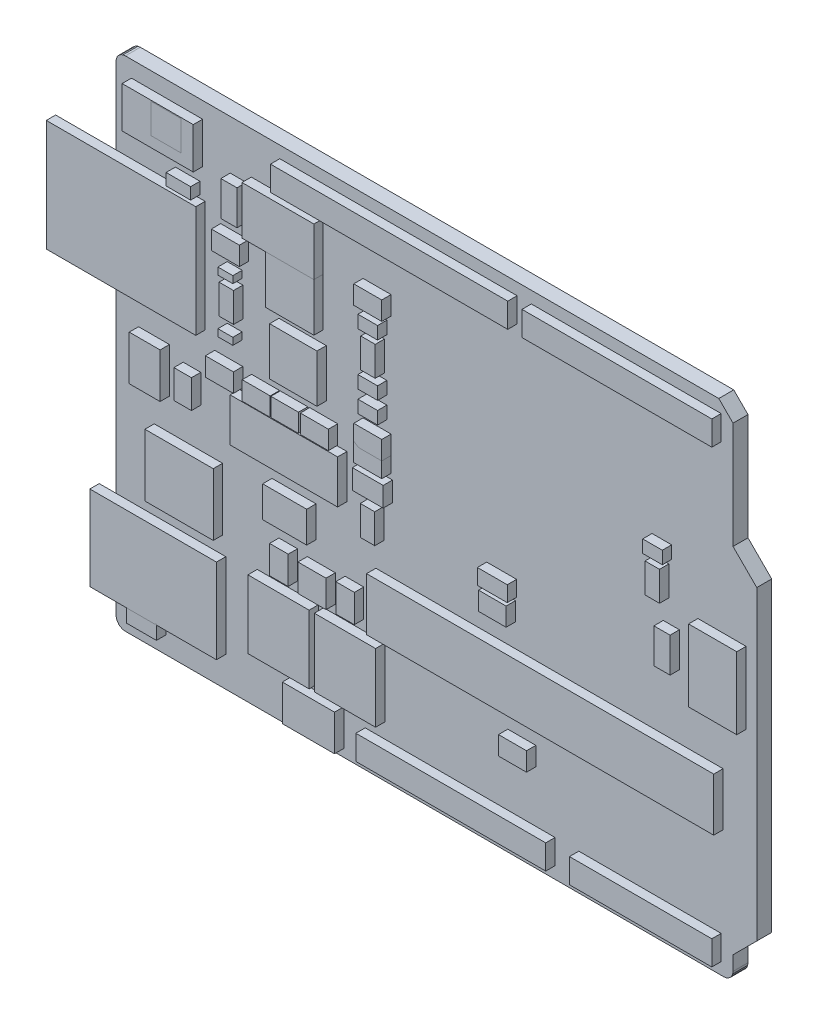
from build123d import *

# Parameters (mm, degrees)
BOARD_DEPTH                 = 1.6
SKETCH2_W                   = 15.24
SKETCH2_H                   = 2.6162
EXTRUDE_1X06_1_DEPTH        = 1
SKETCH3_W                   = 1.9914
SKETCH3_H                   = 2.9968
C0603_ROUND_1_DEPTH         = 1
SKETCH4_W                   = 2.9968
SKETCH4_H                   = 1.9914
C0603_ROUND_2_DEPTH         = 1
SKETCH5_W                   = 1.9914
SKETCH5_H                   = 2.9968
C0603_ROUND_3_DEPTH         = 1
SKETCH6_W                   = 2.9968
SKETCH6_H                   = 1.9914
C0603_ROUND_4_DEPTH         = 1
SKETCH7_W                   = 2.9968
SKETCH7_H                   = 1.9914
C0603_ROUND_5_DEPTH         = 1
SKETCH8_W                   = 2.9968
SKETCH8_H                   = 1.9914
C0603_ROUND_6_DEPTH         = 1
SKETCH9_W                   = 2.9968
SKETCH9_H                   = 1.9914
C0603_ROUND_7_DEPTH         = 1
SKETCH10_W                  = 2.9968
SKETCH10_H                  = 1.9914
C0603_ROUND_8_DEPTH         = 1
SKETCH11_W                  = 2.9968
SKETCH11_H                  = 1.9914
C0603_ROUND_9_DEPTH         = 1
SKETCH12_W                  = 2.9968
SKETCH12_H                  = 1.9914
C0603_ROUND_10_DEPTH        = 1
SKETCH13_W                  = 5.588
SKETCH13_H                  = 3.8608
SMB_1_DEPTH                 = 1
SKETCH14_W                  = 1.7272
SKETCH14_H                  = 3.7084
MINIMELF_1_DEPTH            = 1
SKETCH15_W                  = 1.7272
SKETCH15_H                  = 3.7084
MINIMELF_2_DEPTH            = 1
SKETCH16_W                  = 3.302
SKETCH16_H                  = 4.7854
EXTRUDE_L1812_1_DEPTH       = 1
SKETCH17_W                  = 3.1844
SKETCH17_H                  = 3.1844
FIDUCIA_MOUNT_1_DEPTH       = 1
SKETCH18_W                  = 3.1844
SKETCH18_H                  = 3.1844
FIDUCIA_MOUNT_2_DEPTH       = 1
SKETCH19_W                  = 3.1844
SKETCH19_H                  = 3.1844
FIDUCIA_MOUNT_3_DEPTH       = 1
SKETCH20_W                  = 3.302
SKETCH20_H                  = 2.1082
SJ_1_DEPTH                  = 1
SKETCH21_W                  = 5.1562
SKETCH21_H                  = 7.6962
EXTRUDE_2X03_1_DEPTH        = 1
SKETCH22_W                  = 7.6962
SKETCH22_H                  = 5.1562
EXTRUDE_2X03_2_DEPTH        = 1
SKETCH23_W                  = 25.4
SKETCH23_H                  = 2.6162
EXTRUDE_1X10_1_DEPTH        = 1
SKETCH24_W                  = 20.32
SKETCH24_H                  = 2.6162
EXTRUDE_1X08_1_DEPTH        = 1
SKETCH25_W                  = 20.32
SKETCH25_H                  = 2.6162
EXTRUDE_1X08_2_DEPTH        = 1
SKETCH26_W                  = 5.1562
SKETCH26_H                  = 5.1562
EXTRUDE_2X02_1_DEPTH        = 1
SKETCH27_W                  = 2.1
SKETCH27_H                  = 1.3508
CHIP_LED0805_1_DEPTH        = 1
SKETCH28_W                  = 2.1
SKETCH28_H                  = 1.3508
CHIP_LED0805_2_DEPTH        = 1
SKETCH29_W                  = 2.1
SKETCH29_H                  = 1.3508
CHIP_LED0805_3_DEPTH        = 1
SKETCH30_W                  = 2.1
SKETCH30_H                  = 1.3508
CHIP_LED0805_4_DEPTH        = 1
SKETCH31_W                  = 2.627
SKETCH31_H                  = 1.25
EXTRUDE_0805_1_DEPTH        = 1
SKETCH32_W                  = 6.5508
SKETCH32_H                  = 7.3
PANASONIC_D_1_DEPTH         = 1
SKETCH33_W                  = 6.5508
SKETCH33_H                  = 7.3
PANASONIC_D_2_DEPTH         = 1
SKETCH34_W                  = 2.946
SKETCH34_H                  = 1.966
R0603_ROUND_1_DEPTH         = 1
SKETCH35_W                  = 2.946
SKETCH35_H                  = 1.966
R0603_ROUND_2_DEPTH         = 1
SKETCH36_W                  = 7.6125
SKETCH36_H                  = 4.4
TS42_1_DEPTH                = 1
SKETCH37_W                  = 3.302
SKETCH37_H                  = 2.1082
SJ_2_DEPTH                  = 1
SKETCH38_W                  = 1.5508
SKETCH38_H                  = 3.1508
CAY16_1_DEPTH               = 1
SKETCH39_W                  = 1.5508
SKETCH39_H                  = 3.1508
CAY16_2_DEPTH               = 1
SKETCH40_W                  = 1.5508
SKETCH40_H                  = 3.1508
CAY16_3_DEPTH               = 1
SKETCH41_W                  = 1.5508
SKETCH41_H                  = 3.1508
CAY16_4_DEPTH               = 1
SKETCH42_W                  = 1.8796
SKETCH42_H                  = 3.048
SOT_23_1_DEPTH              = 1
SKETCH44_W                  = 7.3152
SKETCH44_H                  = 6.6548
SOT223_1_DEPTH              = 1
SKETCH45_W                  = 3
SKETCH45_H                  = 2.9202
SOT23_DBV_1_DEPTH           = 1
SKETCH46_W                  = 5.0635
SKETCH46_H                  = 5.127
MLF32_1_DEPTH               = 1
SKETCH47_W                  = 4.7126
SKETCH47_H                  = 3.3262
MSOP08_1_DEPTH              = 1
SKETCH48_W                  = 13.5509
SKETCH48_H                  = 9.0551
POWERSUPPLY_DC_21MM_1_DEPTH = 1
SKETCH49_W                  = 16.004
SKETCH49_H                  = 11.927
PN61729_1_DEPTH             = 1
SKETCH50_W                  = 11.5062
SKETCH50_H                  = 4.6482
QS_1_DEPTH                  = 1
SKETCH51_W                  = 3.2
SKETCH51_H                  = 1.6635
RESONATOR_1_DEPTH           = 1
SKETCH52_W                  = 1.6016
SKETCH52_H                  = 0.7508
CT_CN0603_1_DEPTH           = 1
SKETCH53_W                  = 1.6016
SKETCH53_H                  = 0.7508
CT_CN0603_2_DEPTH           = 1
SKETCH54_W                  = 37.1602
SKETCH54_H                  = 5.6642
DIL28_3_1_DEPTH             = 1


with BuildPart() as part:
    # Sketch1 → BOARD (new body)
    with BuildSketch(Plane.XY):
        Polygon((64.516, 53.34), (66.04, 51.816), (66.04, 40.386), (68.58, 37.846), (68.58, 5.08), (66.04, 2.54), (66.04, 1), (66.005926, 0.741181), (65.906025, 0.5), (65.747107, 0.292893), (65.54, 0.133975), (65.298819, 0.034074), (65.04, 0), (1, 0), (0.741181, 0.034074), (0.5, 0.133975), (0.292893, 0.292893), (0.133975, 0.5), (0.034074, 0.741181), (0, 1), (0, 52.34), (0.034074, 52.598819), (0.133975, 52.84), (0.292893, 53.047107), (0.5, 53.206025), (0.741181, 53.305926), (1, 53.34), align=None)
    extrude(amount=BOARD_DEPTH)


with BuildPart() as body_2:
    # Sketch2 → Extrude 1X06-1 (new body)
    with BuildSketch(Plane.XY.offset(1.6)):
        with Locations((57.15, 2.5781)):
            Rectangle(SKETCH2_W, SKETCH2_H)
    extrude(amount=EXTRUDE_1X06_1_DEPTH)


with BuildPart() as body_3:
    # Sketch3 → C0603-ROUND-1 (new body)
    with BuildSketch(Plane.XY.offset(1.6)):
        with Locations((18.4277, 15.367)):
            Rectangle(SKETCH3_W, SKETCH3_H)
    extrude(amount=C0603_ROUND_1_DEPTH)


with BuildPart() as body_4:
    # Sketch4 → C0603-ROUND-2 (new body)
    with BuildSketch(Plane.XY.offset(1.6)):
        with Locations((12.065, 29.8323)):
            Rectangle(SKETCH4_W, SKETCH4_H)
    extrude(amount=C0603_ROUND_2_DEPTH)


with BuildPart() as body_5:
    # Sketch5 → C0603-ROUND-3 (new body)
    with BuildSketch(Plane.XY.offset(1.6)):
        with Locations((25.5143, 15.367)):
            Rectangle(SKETCH5_W, SKETCH5_H)
    extrude(amount=C0603_ROUND_3_DEPTH)


with BuildPart() as body_6:
    # Sketch6 → C0603-ROUND-4 (new body)
    with BuildSketch(Plane.XY.offset(1.6)):
        with Locations((27.94, 44.4373)):
            Rectangle(SKETCH6_W, SKETCH6_H)
    extrude(amount=C0603_ROUND_4_DEPTH)


with BuildPart() as body_7:
    # Sketch7 → C0603-ROUND-5 (new body)
    with BuildSketch(Plane.XY.offset(1.6)):
        with Locations((27.94, 29.8577)):
            Rectangle(SKETCH7_W, SKETCH7_H)
    extrude(amount=C0603_ROUND_5_DEPTH)


with BuildPart() as body_8:
    # Sketch8 → C0603-ROUND-6 (new body)
    with BuildSketch(Plane.XY.offset(1.6)):
        with Locations((43.434, 10.4013)):
            Rectangle(SKETCH8_W, SKETCH8_H)
    extrude(amount=C0603_ROUND_6_DEPTH)


with BuildPart() as body_9:
    # Sketch9 → C0603-ROUND-7 (new body)
    with BuildSketch(Plane.XY.offset(1.6)):
        with Locations((27.94, 31.5087)):
            Rectangle(SKETCH9_W, SKETCH9_H)
    extrude(amount=C0603_ROUND_7_DEPTH)


with BuildPart() as body_10:
    # Sketch10 → C0603-ROUND-8 (new body)
    with BuildSketch(Plane.XY.offset(1.6)):
        with Locations((12.7, 41.8973)):
            Rectangle(SKETCH10_W, SKETCH10_H)
    extrude(amount=C0603_ROUND_8_DEPTH)


with BuildPart() as body_11:
    # Sketch11 → C0603-ROUND-9 (new body)
    with BuildSketch(Plane.XY.offset(1.6)):
        with Locations((16.002, 29.5783)):
            Rectangle(SKETCH11_W, SKETCH11_H)
    extrude(amount=C0603_ROUND_9_DEPTH)


with BuildPart() as body_12:
    # Sketch12 → C0603-ROUND-10 (new body)
    with BuildSketch(Plane.XY.offset(1.6)):
        with Locations((22.225, 29.6037)):
            Rectangle(SKETCH12_W, SKETCH12_H)
    extrude(amount=C0603_ROUND_10_DEPTH)


with BuildPart() as body_13:
    # Sketch13 → SMB-1 (new body)
    with BuildSketch(Plane.XY.offset(1.6)):
        with Locations((21.59, 2.7686)):
            Rectangle(SKETCH13_W, SKETCH13_H)
    extrude(amount=SMB_1_DEPTH)


with BuildPart() as body_14:
    # Sketch14 → MINIMELF-1 (new body)
    with BuildSketch(Plane.XY.offset(1.6)):
        with Locations((59.436, 27.94)):
            Rectangle(SKETCH14_W, SKETCH14_H)
    extrude(amount=MINIMELF_1_DEPTH)


with BuildPart() as body_15:
    # Sketch15 → MINIMELF-2 (new body)
    with BuildSketch(Plane.XY.offset(1.6)):
        with Locations((13.081, 46.228)):
            Rectangle(SKETCH15_W, SKETCH15_H)
    extrude(amount=MINIMELF_2_DEPTH)


with BuildPart() as body_16:
    # Sketch16 → Extrude L1812-1 (new body)
    with BuildSketch(Plane.XY.offset(1.6)):
        with Locations((4.064, 26.5481)):
            Rectangle(SKETCH16_W, SKETCH16_H)
    extrude(amount=EXTRUDE_L1812_1_DEPTH)


with BuildPart() as body_17:
    # Sketch17 → FIDUCIA-MOUNT-1 (new body)
    with BuildSketch(Plane.XY.offset(1.6)):
        with Locations((6.35, 49.911)):
            Rectangle(SKETCH17_W, SKETCH17_H)
    extrude(amount=FIDUCIA_MOUNT_1_DEPTH)


with BuildPart() as body_18:
    # Sketch18 → FIDUCIA-MOUNT-2 (new body)
    with BuildSketch(Plane.XY.offset(1.6)):
        with Locations((53.84, 16.741)):
            Rectangle(SKETCH18_W, SKETCH18_H)
    extrude(amount=FIDUCIA_MOUNT_2_DEPTH)


with BuildPart() as body_19:
    # Sketch19 → FIDUCIA-MOUNT-3 (new body)
    with BuildSketch(Plane.XY.offset(1.6)):
        with Locations((3.73, 3.41)):
            Rectangle(SKETCH19_W, SKETCH19_H)
    extrude(amount=FIDUCIA_MOUNT_3_DEPTH)


with BuildPart() as body_20:
    # Sketch20 → SJ-1 (new body)
    with BuildSketch(Plane.XY):
        with Locations((11.43, 40.6019)):
            Rectangle(SKETCH20_W, SKETCH20_H)
    extrude(amount=-SJ_1_DEPTH)


with BuildPart() as body_21:
    # Sketch21 → Extrude 2X03-1 (new body)
    with BuildSketch(Plane.XY.offset(1.6)):
        with Locations((64.8589, 27.9781)):
            Rectangle(SKETCH21_W, SKETCH21_H)
    extrude(amount=EXTRUDE_2X03_1_DEPTH)


with BuildPart() as body_22:
    # Sketch22 → Extrude 2X03-2 (new body)
    with BuildSketch(Plane.XY.offset(1.6)):
        with Locations((18.3261, 46.2661)):
            Rectangle(SKETCH22_W, SKETCH22_H)
    extrude(amount=EXTRUDE_2X03_2_DEPTH)


with BuildPart() as body_23:
    # Sketch23 → Extrude 1X10-1 (new body)
    with BuildSketch(Plane.XY.offset(1.6)):
        with Locations((30.226, 50.7619)):
            Rectangle(SKETCH23_W, SKETCH23_H)
    extrude(amount=EXTRUDE_1X10_1_DEPTH)


with BuildPart() as body_24:
    # Sketch24 → Extrude 1X08-1 (new body)
    with BuildSketch(Plane.XY.offset(1.6)):
        with Locations((54.61, 50.7619)):
            Rectangle(SKETCH24_W, SKETCH24_H)
    extrude(amount=EXTRUDE_1X08_1_DEPTH)


with BuildPart() as body_25:
    # Sketch25 → Extrude 1X08-2 (new body)
    with BuildSketch(Plane.XY.offset(1.6)):
        with Locations((36.83, 2.5781)):
            Rectangle(SKETCH25_W, SKETCH25_H)
    extrude(amount=EXTRUDE_1X08_2_DEPTH)


with BuildPart() as body_26:
    # Sketch26 → Extrude 2X02-1 (new body)
    with BuildSketch(Plane.XY.offset(1.6)):
        with Locations((19.5961, 41.1099)):
            Rectangle(SKETCH26_W, SKETCH26_H)
    extrude(amount=EXTRUDE_2X02_1_DEPTH)


with BuildPart() as body_27:
    # Sketch27 → CHIP-LED0805-1 (new body)
    with BuildSketch(Plane.XY.offset(1.6)):
        with Locations((27.94, 42.1644)):
            Rectangle(SKETCH27_W, SKETCH27_H)
    extrude(amount=CHIP_LED0805_1_DEPTH)


with BuildPart() as body_28:
    # Sketch28 → CHIP-LED0805-2 (new body)
    with BuildSketch(Plane.XY.offset(1.6)):
        with Locations((58.42, 36.5764)):
            Rectangle(SKETCH28_W, SKETCH28_H)
    extrude(amount=CHIP_LED0805_2_DEPTH)


with BuildPart() as body_29:
    # Sketch29 → CHIP-LED0805-3 (new body)
    with BuildSketch(Plane.XY.offset(1.6)):
        with Locations((27.94, 34.2896)):
            Rectangle(SKETCH29_W, SKETCH29_H)
    extrude(amount=CHIP_LED0805_3_DEPTH)


with BuildPart() as body_30:
    # Sketch30 → CHIP-LED0805-4 (new body)
    with BuildSketch(Plane.XY.offset(1.6)):
        with Locations((27.94, 36.5756)):
            Rectangle(SKETCH30_W, SKETCH30_H)
    extrude(amount=CHIP_LED0805_4_DEPTH)


with BuildPart() as body_31:
    # Sketch31 → Extrude 0805-1 (new body)
    with BuildSketch(Plane.XY.offset(1.6)):
        with Locations((7.67, 45.085)):
            Rectangle(SKETCH31_W, SKETCH31_H)
    extrude(amount=EXTRUDE_0805_1_DEPTH)


with BuildPart() as body_32:
    # Sketch32 → PANASONIC_D-1 (new body)
    with BuildSketch(Plane.XY.offset(1.6)):
        with Locations((25.5016, 9.144)):
            Rectangle(SKETCH32_W, SKETCH32_H)
    extrude(amount=PANASONIC_D_1_DEPTH)


with BuildPart() as body_33:
    # Sketch33 → PANASONIC_D-2 (new body)
    with BuildSketch(Plane.XY.offset(1.6)):
        with Locations((18.3896, 9.144)):
            Rectangle(SKETCH33_W, SKETCH33_H)
    extrude(amount=PANASONIC_D_2_DEPTH)


with BuildPart() as body_34:
    # Sketch34 → R0603-ROUND-1 (new body)
    with BuildSketch(Plane.XY.offset(1.6)):
        with Locations((19.05, 29.591)):
            Rectangle(SKETCH34_W, SKETCH34_H)
    extrude(amount=R0603_ROUND_1_DEPTH)


with BuildPart() as body_35:
    # Sketch35 → R0603-ROUND-2 (new body)
    with BuildSketch(Plane.XY.offset(1.6)):
        with Locations((41.275, 22.733)):
            Rectangle(SKETCH35_W, SKETCH35_H)
    extrude(amount=R0603_ROUND_2_DEPTH)


with BuildPart() as body_36:
    # Sketch36 → TS42-1 (new body)
    with BuildSketch(Plane.XY.offset(1.6)):
        with Locations((5.45725, 49.403)):
            Rectangle(SKETCH36_W, SKETCH36_H)
    extrude(amount=TS42_1_DEPTH)


with BuildPart() as body_37:
    # Sketch37 → SJ-2 (new body)
    with BuildSketch(Plane.XY.offset(1.6)):
        with Locations((27.94, 27.2669)):
            Rectangle(SKETCH37_W, SKETCH37_H)
    extrude(amount=SJ_2_DEPTH)


with BuildPart() as body_38:
    # Sketch38 → CAY16-1 (new body)
    with BuildSketch(Plane.XY.offset(1.6)):
        with Locations((27.9146, 23.8506)):
            Rectangle(SKETCH38_W, SKETCH38_H)
    extrude(amount=CAY16_1_DEPTH)


with BuildPart() as body_39:
    # Sketch39 → CAY16-2 (new body)
    with BuildSketch(Plane.XY.offset(1.6)):
        with Locations((27.9654, 39.3954)):
            Rectangle(SKETCH39_W, SKETCH39_H)
    extrude(amount=CAY16_2_DEPTH)


with BuildPart() as body_40:
    # Sketch40 → CAY16-3 (new body)
    with BuildSketch(Plane.XY.offset(1.6)):
        with Locations((12.8016, 36.8046)):
            Rectangle(SKETCH40_W, SKETCH40_H)
    extrude(amount=CAY16_3_DEPTH)


with BuildPart() as body_41:
    # Sketch41 → CAY16-4 (new body)
    with BuildSketch(Plane.XY.offset(1.6)):
        with Locations((58.3946, 33.7566)):
            Rectangle(SKETCH41_W, SKETCH41_H)
    extrude(amount=CAY16_4_DEPTH)


with BuildPart() as body_42:
    # Sketch42 → SOT-23-1 (new body)
    with BuildSketch(Plane.XY.offset(1.6)):
        with Locations((8.128, 26.5176)):
            Rectangle(SKETCH42_W, SKETCH42_H)
    extrude(amount=SOT_23_1_DEPTH)


with BuildPart() as body_43:
    # Sketch44 → SOT223-1 (new body)
    with BuildSketch(Plane.XY.offset(1.6)):
        with Locations((7.747, 17.4498)):
            Rectangle(SKETCH44_W, SKETCH44_H)
    extrude(amount=SOT223_1_DEPTH)


with BuildPart() as body_44:
    # Sketch45 → SOT23-DBV-1 (new body)
    with BuildSketch(Plane.XY.offset(1.6)):
        with Locations((21.971, 15.2019)):
            Rectangle(SKETCH45_W, SKETCH45_H)
    extrude(amount=SOT23_DBV_1_DEPTH)


with BuildPart() as body_45:
    # Sketch46 → MLF32-1 (new body)
    with BuildSketch(Plane.XY.offset(1.6)):
        with Locations((19.97075, 34.671)):
            Rectangle(SKETCH46_W, SKETCH46_H)
    extrude(amount=MLF32_1_DEPTH)


with BuildPart() as body_46:
    # Sketch47 → MSOP08-1 (new body)
    with BuildSketch(Plane.XY.offset(1.6)):
        with Locations((19.0506, 20.3571)):
            Rectangle(SKETCH47_W, SKETCH47_H)
    extrude(amount=MSOP08_1_DEPTH)


with BuildPart() as body_47:
    # Sketch48 → POWERSUPPLY_DC-21MM-1 (new body)
    with BuildSketch(Plane.XY.offset(1.6)):
        with Locations((4.97205, 7.76605)):
            Rectangle(SKETCH48_W, SKETCH48_H)
    extrude(amount=POWERSUPPLY_DC_21MM_1_DEPTH)


with BuildPart() as body_48:
    # Sketch49 → PN61729-1 (new body)
    with BuildSketch(Plane.XY.offset(1.6)):
        with Locations((1.535, 38.1635)):
            Rectangle(SKETCH49_W, SKETCH49_H)
    extrude(amount=PN61729_1_DEPTH)


with BuildPart() as body_49:
    # Sketch50 → QS-1 (new body)
    with BuildSketch(Plane.XY.offset(1.6)):
        with Locations((18.9611, 26.2001)):
            Rectangle(SKETCH50_W, SKETCH50_H)
    extrude(amount=QS_1_DEPTH)


with BuildPart() as body_50:
    # Sketch51 → RESONATOR-1 (new body)
    with BuildSketch(Plane.XY.offset(1.6)):
        with Locations((41.275, 24.92375)):
            Rectangle(SKETCH51_W, SKETCH51_H)
    extrude(amount=RESONATOR_1_DEPTH)


with BuildPart() as body_51:
    # Sketch52 → CT_CN0603-1 (new body)
    with BuildSketch(Plane.XY.offset(1.6)):
        with Locations((12.7, 39.3446)):
            Rectangle(SKETCH52_W, SKETCH52_H)
    extrude(amount=CT_CN0603_1_DEPTH)


with BuildPart() as body_52:
    # Sketch53 → CT_CN0603-2 (new body)
    with BuildSketch(Plane.XY.offset(1.6)):
        with Locations((12.7, 33.6296)):
            Rectangle(SKETCH53_W, SKETCH53_H)
    extrude(amount=CT_CN0603_2_DEPTH)


with BuildPart() as body_53:
    # Sketch54 → DIL28-3-1 (new body)
    with BuildSketch(Plane.XY.offset(1.6)):
        with Locations((46.3931, 16.4211)):
            Rectangle(SKETCH54_W, SKETCH54_H)
    extrude(amount=DIL28_3_1_DEPTH)


solid = Compound([part.part, body_2.part, body_3.part, body_4.part, body_5.part, body_6.part, body_7.part, body_8.part, body_9.part, body_10.part, body_11.part, body_12.part, body_13.part, body_14.part, body_15.part, body_16.part, body_17.part, body_18.part, body_19.part, body_20.part, body_21.part, body_22.part, body_23.part, body_24.part, body_25.part, body_26.part, body_27.part, body_28.part, body_29.part, body_30.part, body_31.part, body_32.part, body_33.part, body_34.part, body_35.part, body_36.part, body_37.part, body_38.part, body_39.part, body_40.part, body_41.part, body_42.part, body_43.part, body_44.part, body_45.part, body_46.part, body_47.part, body_48.part, body_49.part, body_50.part, body_51.part, body_52.part, body_53.part])
